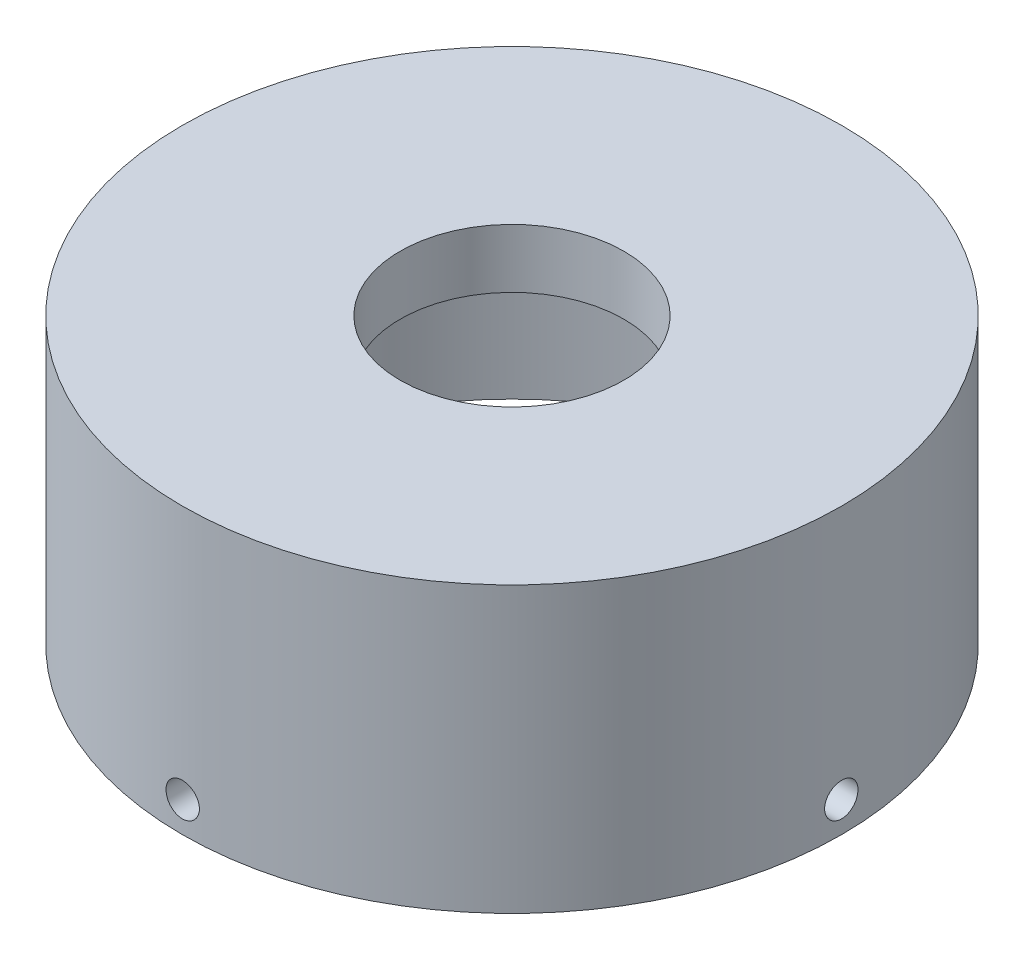
from build123d import *

# Parameters (mm, degrees)
SKETCH1_R           = 42.672
SKETCH1_R_2         = 38.862
BOSS_EXTRUDE1_DEPTH = 29.21
SKETCH2_R           = 42.672
SKETCH2_R_2         = 14.478
BOSS_EXTRUDE2_DEPTH = 7.62
SKETCH3_R           = 2.159
CUT_EXTRUDE1_DEPTH  = 43.672
CIRPATTERN1_COUNT   = 4


with BuildPart() as part:
    # Sketch1 → Boss-Extrude1 (new body)
    with BuildSketch(Plane(origin=(0, 0, 0), x_dir=(1, 0, 0), z_dir=(0, 1, 0))):
        Circle(SKETCH1_R)
        Circle(SKETCH1_R_2, mode=Mode.SUBTRACT)
    extrude(amount=BOSS_EXTRUDE1_DEPTH)

    # Sketch2 → Boss-Extrude2 (add)
    with BuildSketch(Plane(origin=(0, 29.21, 0), x_dir=(1, 0, 0), z_dir=(0, 1, 0))):
        Circle(SKETCH2_R)
        Circle(SKETCH2_R_2, mode=Mode.SUBTRACT)
    extrude(amount=BOSS_EXTRUDE2_DEPTH)

    # Sketch3 → Cut-Extrude1 (cut, symmetric)
    with BuildSketch(Plane.XY):
        with Locations((0, 3.937)):
            Circle(SKETCH3_R)
    cut_extrude1 = extrude(amount=CUT_EXTRUDE1_DEPTH, both=True, mode=Mode.SUBTRACT)

    # CirPattern1: Cut-Extrude1 ×4 about axis
    cirpattern1_axis = Axis((0, 29.21, 0), (0, -1, 0))
    for i in range(1, CIRPATTERN1_COUNT):
        add(cut_extrude1.rotate(cirpattern1_axis, i * 360 / CIRPATTERN1_COUNT), mode=Mode.SUBTRACT)


solid = part.part
